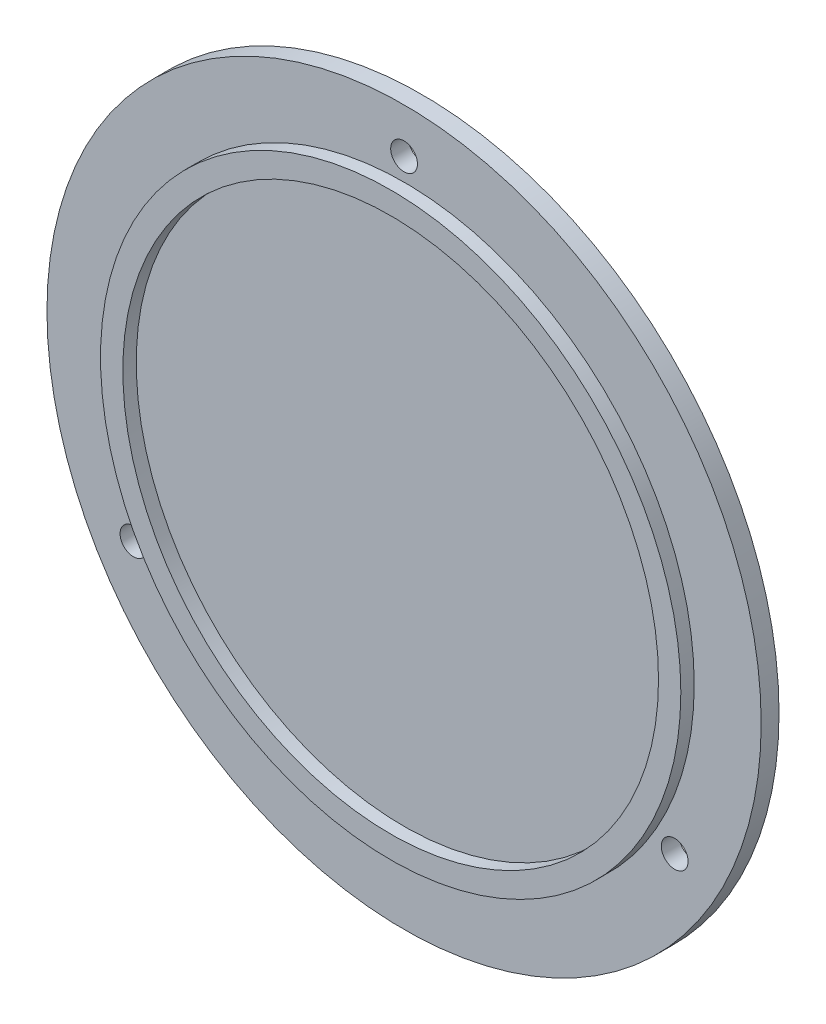
from build123d import *

# Parameters (mm, degrees)
SKETCH1_R           = 80
BOSS_EXTRUDE1_DEPTH = 4
SKETCH2_R           = 65
SKETCH2_R_2         = 60
BOSS_EXTRUDE2_DEPTH = 3
SKETCH3_R           = 3
CUT_EXTRUDE2_DEPTH  = 8


with BuildPart() as part:
    # Sketch1 → Boss-Extrude1 (new body)
    with BuildSketch(Plane.XY):
        Circle(SKETCH1_R)
    extrude(amount=BOSS_EXTRUDE1_DEPTH)

    # Sketch2 → Boss-Extrude2 (add)
    with BuildSketch(Plane.XY.offset(4)):
        Circle(SKETCH2_R)
        Circle(SKETCH2_R_2, mode=Mode.SUBTRACT)
    extrude(amount=BOSS_EXTRUDE2_DEPTH)

    # Sketch3 → Cut-Extrude2 (cut, through all)
    with BuildSketch(Plane(origin=(0, 0, 0), x_dir=(-1, 0, 0), z_dir=(0, 0, -1))):
        with Locations((0, 70)):
            Circle(SKETCH3_R)
        with Locations((60.621778265, -35)):
            Circle(SKETCH3_R)
        with Locations((-60.621778265, -35)):
            Circle(SKETCH3_R)
    extrude(amount=-CUT_EXTRUDE2_DEPTH, mode=Mode.SUBTRACT)


solid = part.part
